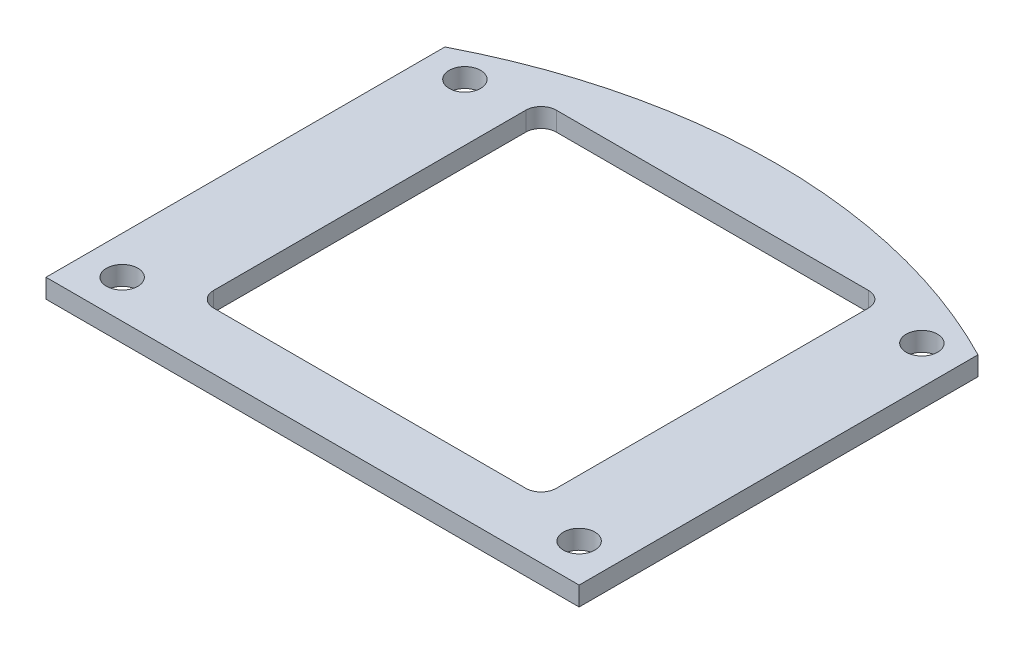
from build123d import *

# Parameters (mm, degrees)
SKETCH1_R           = 1.65
SKETCH1_W           = 36
SKETCH1_H           = 36
BOSS_EXTRUDE1_DEPTH = 2
FILLET1_R           = 1.6


with BuildPart() as part:
    # Sketch1 → Boss-Extrude1 (new body)
    with BuildSketch(Plane(origin=(0, 0, 0), x_dir=(1, 0, 0), z_dir=(0, 1, 0))):
        with BuildLine():
            Line((-28, -24), (28, -24))
            Line((28, -24), (28, 17.89570392))
            ThreePointArc((28, 17.89570392), (0, 24.701428863), (-28, 17.89570392))
            Line((-28, 17.89570392), (-28, -24))
        make_face()
        with Locations((-24, 16)):
            Circle(SKETCH1_R, mode=Mode.SUBTRACT)
        with Locations((-24, -20)):
            Circle(SKETCH1_R, mode=Mode.SUBTRACT)
        with Locations((24, 16)):
            Circle(SKETCH1_R, mode=Mode.SUBTRACT)
        with Locations((24, -20)):
            Circle(SKETCH1_R, mode=Mode.SUBTRACT)
        Rectangle(SKETCH1_W, SKETCH1_H, mode=Mode.SUBTRACT)
    extrude(amount=BOSS_EXTRUDE1_DEPTH)

    # Fillet1
    fillet1_edges = [part.edges().sort_by_distance(p)[0] for p in [
        (18, 1, -18),
        (-18, 1, -18),
        (-18, 1, 18),
        (18, 1, 18),
    ]]
    fillet(fillet1_edges, radius=FILLET1_R)


solid = part.part
